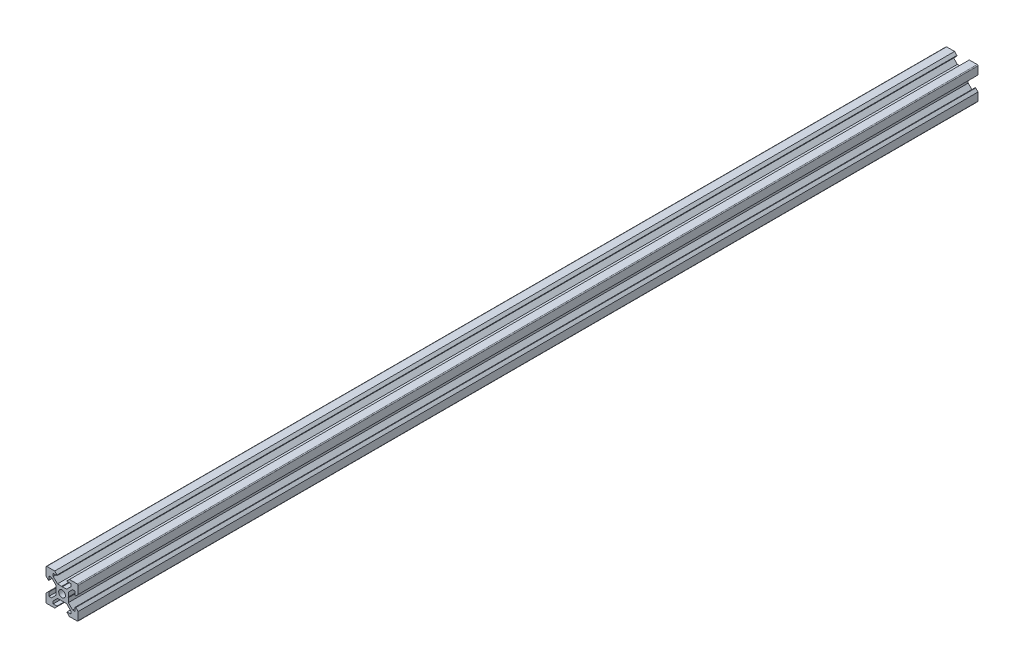
from build123d import *

# Parameters (mm, degrees)
SKETCH1_R           = 2.1
BOSS_EXTRUDE1_DEPTH = 560


with BuildPart() as part:
    # Sketch1 → Boss-Extrude1 (new body)
    with BuildSketch(Plane.XY):
        with BuildLine():
            Line((4.58, -10), (9.5, -10))
            ThreePointArc((9.5, -10), (9.853553391, -9.853553391), (10, -9.5))
            Line((10, -9.5), (10, -4.58))
            Line((10, -4.58), (8.545, -3.125))
            Line((8.545, -3.125), (8.2, -3.125))
            Line((8.2, -3.125), (8.2, -5.5))
            Line((8.2, -5.5), (6.560660172, -5.5))
            Line((6.560660172, -5.5), (3.9, -2.839339828))
            Line((3.9, -2.839339828), (3.9, -0.21))
            Line((3.9, -0.21), (3.69, 0))
            Line((3.69, 0), (3.9, 0.21))
            Line((3.9, 0.21), (3.9, 2.839339828))
            Line((3.9, 2.839339828), (6.560660172, 5.5))
            Line((6.560660172, 5.5), (8.2, 5.5))
            Line((8.2, 5.5), (8.2, 3.125))
            Line((8.2, 3.125), (8.545, 3.125))
            Line((8.545, 3.125), (10, 4.58))
            Line((10, 4.58), (10, 9.5))
            ThreePointArc((10, 9.5), (9.853553391, 9.853553391), (9.5, 10))
            Line((9.5, 10), (4.58, 10))
            Line((4.58, 10), (3.125, 8.545))
            Line((3.125, 8.545), (3.125, 8.2))
            Line((3.125, 8.2), (5.5, 8.2))
            Line((5.5, 8.2), (5.5, 6.560660172))
            Line((5.5, 6.560660172), (2.839339828, 3.9))
            Line((2.839339828, 3.9), (0.21, 3.9))
            Line((0.21, 3.9), (0, 3.69))
            Line((0, 3.69), (-0.21, 3.9))
            Line((-0.21, 3.9), (-2.839339828, 3.9))
            Line((-2.839339828, 3.9), (-5.5, 6.560660172))
            Line((-5.5, 6.560660172), (-5.5, 8.2))
            Line((-5.5, 8.2), (-3.125, 8.2))
            Line((-3.125, 8.2), (-3.125, 8.545))
            Line((-3.125, 8.545), (-4.58, 10))
            Line((-4.58, 10), (-9.5, 10))
            ThreePointArc((-9.5, 10), (-9.853553391, 9.853553391), (-10, 9.5))
            Line((-10, 9.5), (-10, 4.58))
            Line((-10, 4.58), (-8.545, 3.125))
            Line((-8.545, 3.125), (-8.2, 3.125))
            Line((-8.2, 3.125), (-8.2, 5.5))
            Line((-8.2, 5.5), (-6.560660172, 5.5))
            Line((-6.560660172, 5.5), (-3.9, 2.839339828))
            Line((-3.9, 2.839339828), (-3.9, 0.21))
            Line((-3.9, 0.21), (-3.69, 0))
            Line((-3.69, 0), (-3.9, -0.21))
            Line((-3.9, -0.21), (-3.9, -2.839339828))
            Line((-3.9, -2.839339828), (-6.560660172, -5.5))
            Line((-6.560660172, -5.5), (-8.2, -5.5))
            Line((-8.2, -5.5), (-8.2, -3.125))
            Line((-8.2, -3.125), (-8.545, -3.125))
            Line((-8.545, -3.125), (-10, -4.58))
            Line((-10, -4.58), (-10, -9.5))
            ThreePointArc((-10, -9.5), (-9.853553391, -9.853553391), (-9.5, -10))
            Line((-9.5, -10), (-4.58, -10))
            Line((-4.58, -10), (-3.125, -8.545))
            Line((-3.125, -8.545), (-3.125, -8.2))
            Line((-3.125, -8.2), (-5.5, -8.2))
            Line((-5.5, -8.2), (-5.5, -6.560660172))
            Line((-5.5, -6.560660172), (-2.839339828, -3.9))
            Line((-2.839339828, -3.9), (-0.21, -3.9))
            Line((-0.21, -3.9), (0, -3.69))
            Line((0, -3.69), (0.21, -3.9))
            Line((0.21, -3.9), (2.839339828, -3.9))
            Line((2.839339828, -3.9), (5.5, -6.560660172))
            Line((5.5, -6.560660172), (5.5, -8.2))
            Line((5.5, -8.2), (3.125, -8.2))
            Line((3.125, -8.2), (3.125, -8.545))
            Line((3.125, -8.545), (4.58, -10))
        make_face()
        Circle(SKETCH1_R, mode=Mode.SUBTRACT)
    extrude(amount=BOSS_EXTRUDE1_DEPTH)


solid = part.part
